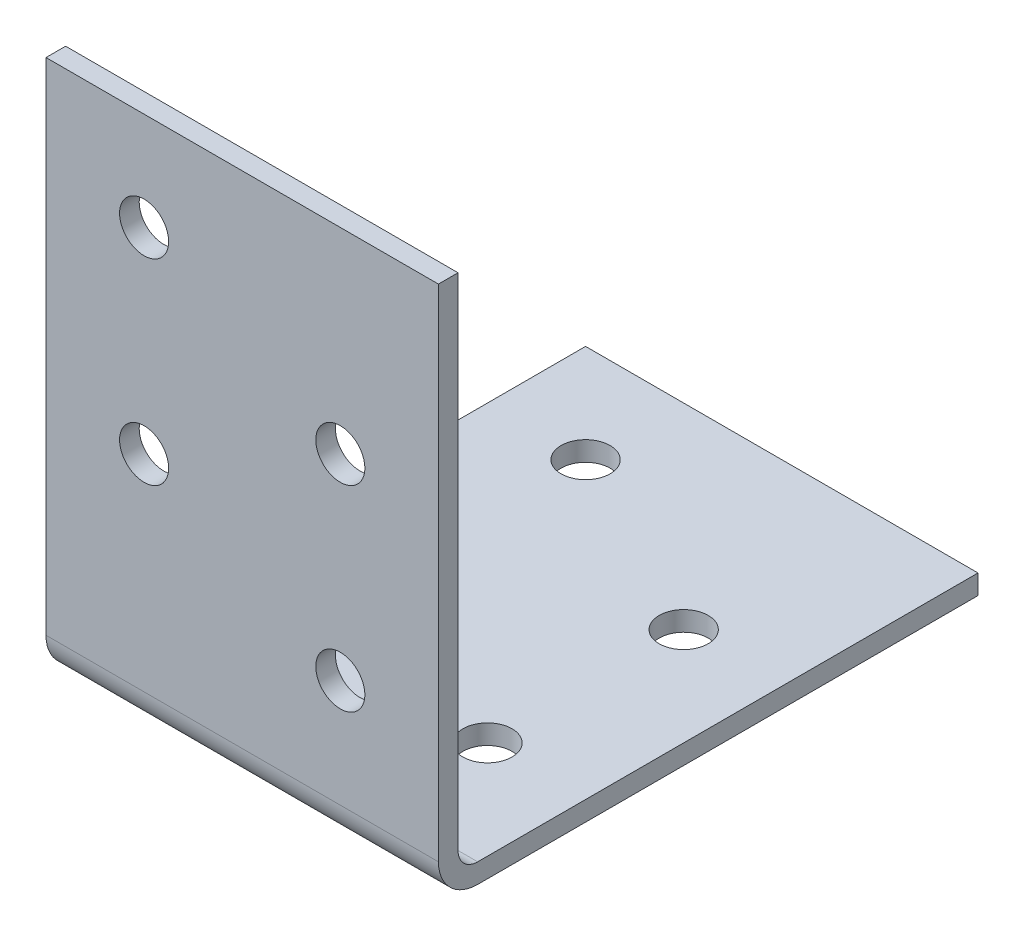
from build123d import *

# Parameters (mm, degrees)
BOSS_EXTRU_1_DEPTH            = 20
DIAM_TRE_DU_PER_AGE_5_0_5_1_D = 5
DIAM_TRE_DU_PER_AGE_5_0_5_2_D = 5


with BuildPart() as part:
    # Esquisse1 → Boss.-Extru.1 (new body, symmetric)
    with BuildSketch(Plane(origin=(0, 0, 0), x_dir=(0, 0, -1), z_dir=(1, 0, 0))):
        with BuildLine():
            Line((0, 55), (0, 4))
            ThreePointArc((0, 4), (1.171572875, 1.171572875), (4, 0))
            Line((4, 0), (55, 0))
            Line((55, 0), (55, 2))
            Line((55, 2), (4, 2))
            ThreePointArc((4, 2), (2.585786438, 2.585786438), (2, 4))
            Line((2, 4), (2, 55))
            Line((2, 55), (0, 55))
        make_face()
    extrude(amount=BOSS_EXTRU_1_DEPTH, both=True)

    # Diamètre du perçage Ø5.0 (5)1 (through all)
    with Locations(Plane(origin=(0, 2, 0), x_dir=(1, 0, 0), z_dir=(0, 1, 0))):
        with Locations((-10, 45), (-10, 25), (10, 35), (10, 15)):
            Hole(DIAM_TRE_DU_PER_AGE_5_0_5_1_D / 2)

    # Diamètre du perçage Ø5.0 (5)2 (through all)
    with Locations(Plane(origin=(0, 0, -2), x_dir=(-1, 0, 0), z_dir=(0, 0, -1))):
        with Locations((-10, 15), (-10, 35), (10, 25), (10, 45)):
            Hole(DIAM_TRE_DU_PER_AGE_5_0_5_2_D / 2)


solid = part.part
